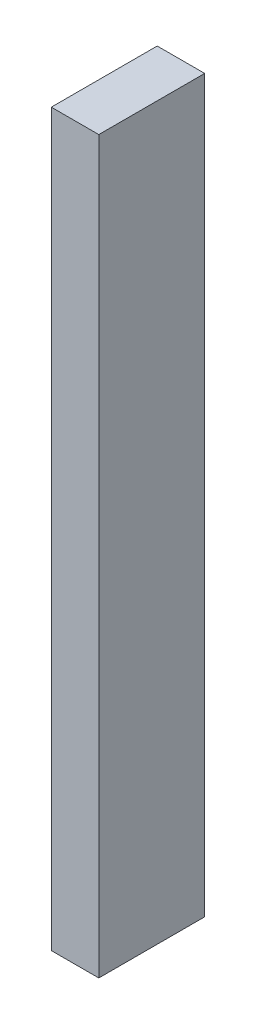
from build123d import *

# Parameters (mm, degrees)
SKETCH1_W           = 13
SKETCH1_H           = 200
BOSS_EXTRUDE1_DEPTH = 29


with BuildPart() as part:
    # Sketch1 → Boss-Extrude1 (new body)
    with BuildSketch(Plane.XY):
        Rectangle(SKETCH1_W, SKETCH1_H)
    extrude(amount=BOSS_EXTRUDE1_DEPTH)


solid = part.part
